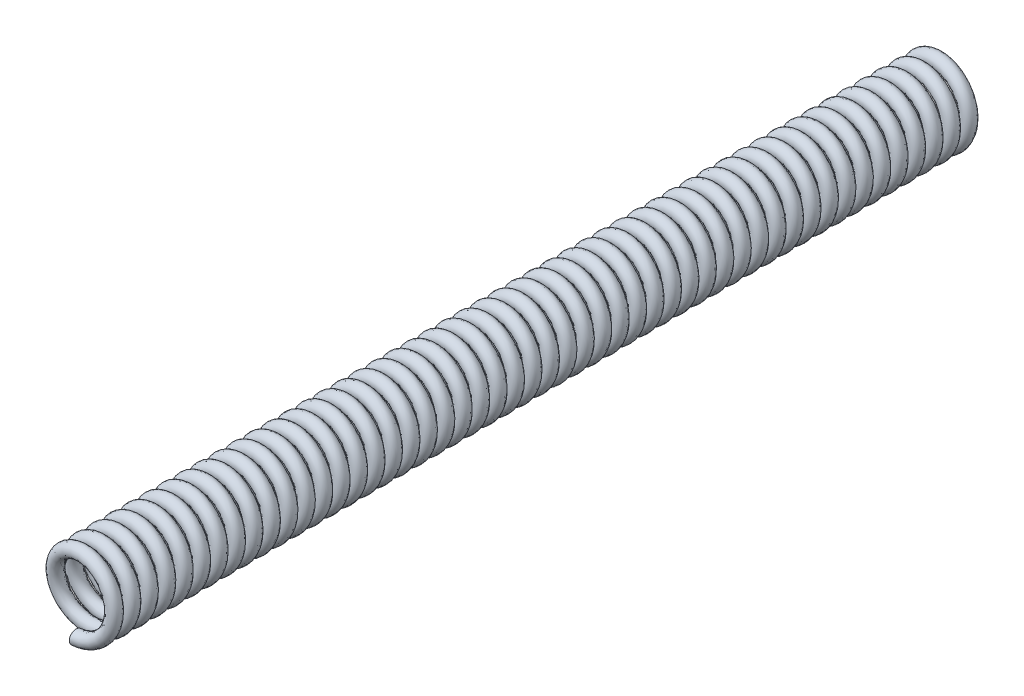
from build123d import *

# Parameters (mm, degrees)
SWEEP1_PITCH       = 0.4953
SWEEP1_HEIGHT      = 24.765
SWEEP1_RADIUS      = 0.9525
SWEEP1_START_ANGLE = -90
SKETCH2_R          = 0.1905


with BuildPart() as part:
    # Sweep1: sweep along a helix
    with BuildLine() as sweep1_path:
        add(Helix(SWEEP1_PITCH, SWEEP1_HEIGHT, SWEEP1_RADIUS, center=(0, 0, 0), direction=(0, 0, 1), lefthand=True, mode=Mode.PRIVATE).rotate(Axis((0, 0, 0), (0, 0, 1)), SWEEP1_START_ANGLE))
    # Sketch2 → Sweep1 (sweep)
    with BuildSketch(Plane(origin=(0, 0, 0), x_dir=(0, 0, -1), z_dir=(1, 0, 0))):
        with Locations((0, -0.9525)):
            Circle(SKETCH2_R)
    sweep(path=sweep1_path.line, is_frenet=True)


solid = part.part
